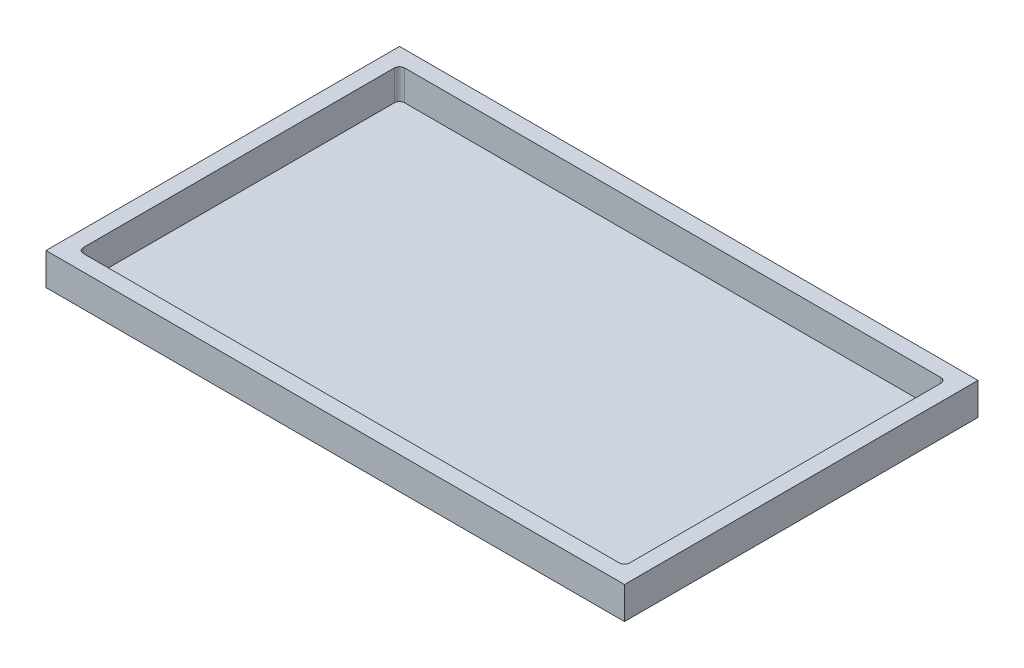
from build123d import *

# Parameters (mm, degrees)
SKETCH1_W           = 900
SKETCH1_H           = 550
BOSS_EXTRUDE1_DEPTH = 50
SKETCH2_W           = 850
SKETCH2_H           = 500
CUT_EXTRUDE1_DEPTH  = 47
FILLET1_R           = 8


with BuildPart() as part:
    # Sketch1 → Boss-Extrude1 (new body)
    with BuildSketch(Plane(origin=(0, 0, 0), x_dir=(1, 0, 0), z_dir=(0, 1, 0))):
        Rectangle(SKETCH1_W, SKETCH1_H)
    extrude(amount=BOSS_EXTRUDE1_DEPTH)

    # Sketch2 → Cut-Extrude1 (cut)
    with BuildSketch(Plane(origin=(0, 50, 0), x_dir=(1, 0, 0), z_dir=(0, 1, 0))):
        Rectangle(SKETCH2_W, SKETCH2_H)
    extrude(amount=-CUT_EXTRUDE1_DEPTH, mode=Mode.SUBTRACT)

    # Fillet1
    fillet1_edges = [part.edges().sort_by_distance(p)[0] for p in [
        (425, 26.5, 250),
        (-425, 26.5, 250),
        (-425, 26.5, -250),
        (425, 26.5, -250),
    ]]
    fillet(fillet1_edges, radius=FILLET1_R)


solid = part.part
